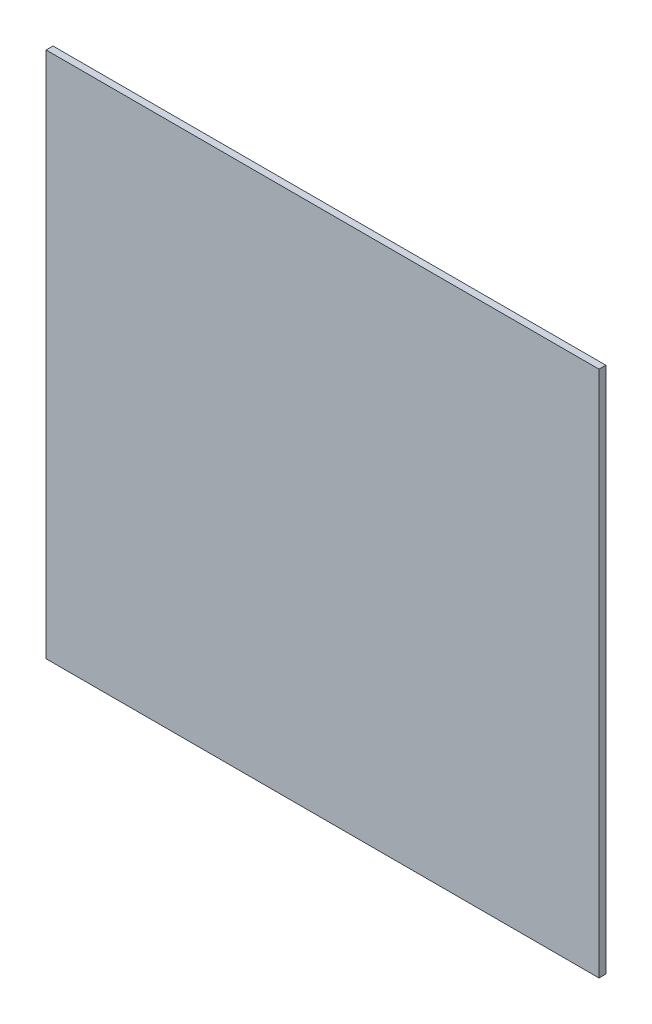
from build123d import *

# Parameters (mm, degrees)
SKETCH1_W           = 958.85
SKETCH1_H           = 914.4
BOSS_EXTRUDE1_DEPTH = 11.90625


with BuildPart() as part:
    # Sketch1 → Boss-Extrude1 (new body)
    with BuildSketch(Plane.XY):
        Rectangle(SKETCH1_W, SKETCH1_H)
    extrude(amount=BOSS_EXTRUDE1_DEPTH)


solid = part.part
